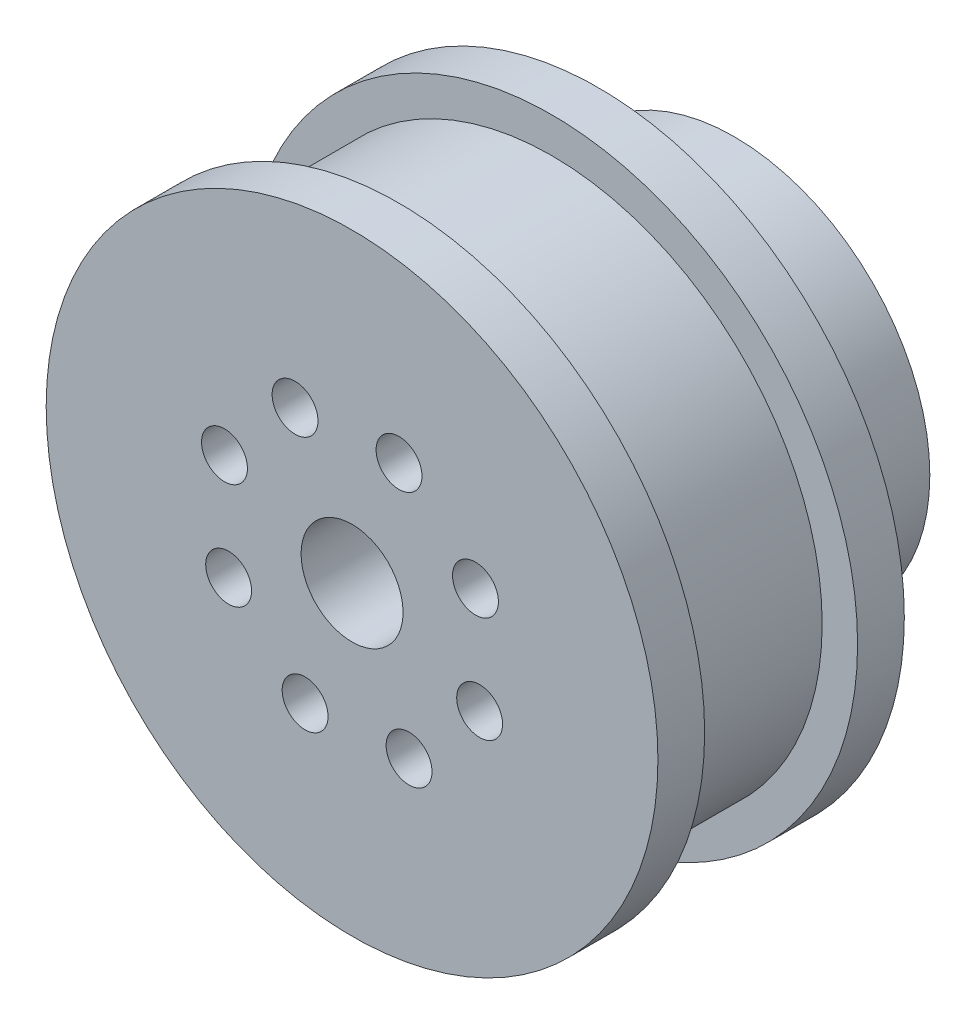
from build123d import *

# Parameters (mm, degrees)
ESQUISSE1_R                  = 18
BOSS_EXTRU_2_DEPTH           = 2.75
ESQUISSE2_R                  = 15.915
BOSS_EXTRU_3_DEPTH           = 9
ESQUISSE3_R                  = 18
BOSS_EXTRU_4_DEPTH           = 2.75
ESQUISSE4_R                  = 11.5
BOSS_EXTRU_5_DEPTH           = 8
ESQUISSE5_R                  = 3
ENL_V_MAT_EXTRU_1_DEPTH      = 23.5
ESQUISSE6_R                  = 4
ENL_V_MAT_EXTRU_2_DEPTH      = 10
ESQUISSE7_R                  = 1.35
ENL_V_MAT_EXTRU_3_DEPTH      = 23.5
R_P_TITION_CIRCULAIRE1_COUNT = 8


with BuildPart() as part:
    # Esquisse1 → Boss.-Extru.2 (new body)
    with BuildSketch(Plane.XY):
        Circle(ESQUISSE1_R)
    extrude(amount=BOSS_EXTRU_2_DEPTH)

    # Esquisse2 → Boss.-Extru.3 (add)
    with BuildSketch(Plane.XY.offset(2.75)):
        Circle(ESQUISSE2_R)
    extrude(amount=BOSS_EXTRU_3_DEPTH)

    # Esquisse3 → Boss.-Extru.4 (add)
    with BuildSketch(Plane.XY.offset(11.75)):
        Circle(ESQUISSE3_R)
    extrude(amount=BOSS_EXTRU_4_DEPTH)

    # Esquisse4 → Boss.-Extru.5 (add)
    with BuildSketch(Plane(origin=(0, 0, 0), x_dir=(-1, 0, 0), z_dir=(0, 0, -1))):
        with Locations(Location((0, 0, 0), (0, 0, 180))):  # turned: the seam where the file's is
            Circle(ESQUISSE4_R)
    extrude(amount=BOSS_EXTRU_5_DEPTH)

    # Esquisse5 → Enlèv. mat.-Extru.1 (cut, through all)
    with BuildSketch(Plane(origin=(0, 0, -8), x_dir=(-1, 0, 0), z_dir=(0, 0, -1))):
        Circle(ESQUISSE5_R)
    extrude(amount=-ENL_V_MAT_EXTRU_1_DEPTH, mode=Mode.SUBTRACT)

    # Esquisse6 → Enlèv. mat.-Extru.2 (cut)
    with BuildSketch(Plane(origin=(0, 0, -8), x_dir=(-1, 0, 0), z_dir=(0, 0, -1))):
        Circle(ESQUISSE6_R)
    extrude(amount=-ENL_V_MAT_EXTRU_2_DEPTH, mode=Mode.SUBTRACT)

    # Esquisse7 → Enlèv. mat.-Extru.3 (cut, through all)
    with BuildSketch(Plane(origin=(0, 0, -8), x_dir=(-1, 0, 0), z_dir=(0, 0, -1))):
        with Locations((3.354474935, 7.26274727)):
            Circle(ESQUISSE7_R)
    enl_v_mat_extru_3 = extrude(amount=-ENL_V_MAT_EXTRU_3_DEPTH, mode=Mode.SUBTRACT)

    # Répétition circulaire1: Enlèv. mat.-Extru.3 ×8 about axis
    r_p_tition_circulaire1_axis = Axis((0, 0, 0), (0, 0, 1))
    for i in range(1, R_P_TITION_CIRCULAIRE1_COUNT):
        add(enl_v_mat_extru_3.rotate(r_p_tition_circulaire1_axis, i * 360 / R_P_TITION_CIRCULAIRE1_COUNT), mode=Mode.SUBTRACT)


solid = part.part
